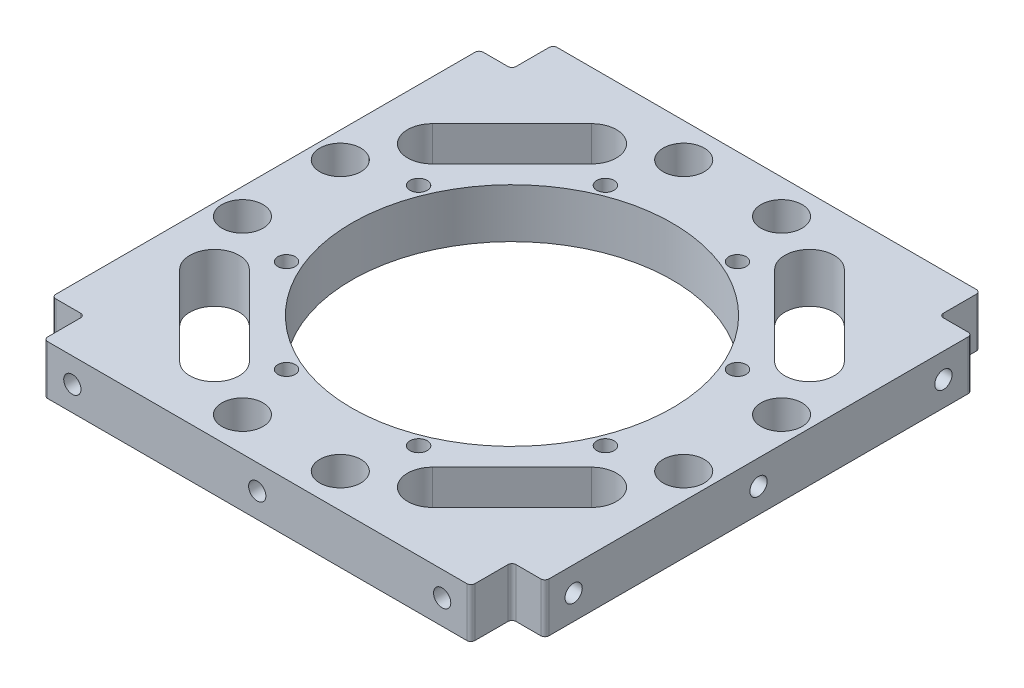
from build123d import *

# Parameters (mm, degrees)
SKETCH_1_W                  = 120
SKETCH_1_H                  = 124
SKETCH_1_R                  = 39
EXTRUDE_1_DEPTH             = 6
SKETCH_2_R                  = 2.1
CUT_EXTRUDE_1_DEPTH         = 13
PATTERN_CIRCULAR_1_COUNT    = 8
SKETCH_3_R                  = 1.5
CUT_EXTRUDE_2_DEPTH         = 15
SKETCH_4_R                  = 1.5
CUT_EXTRUDE_5_DEPTH         = 10
HOLE_WIZARD_M5_1_AT_2_COUNT = 2
HOLE_WIZARD_M5_1_AT_2_PITCH = 45
HOLE_WIZARD_M5_1_AT_3_COUNT = 2
HOLE_WIZARD_M5_1_AT_3_PITCH = 90
HOLE_WIZARD_M5_2_AT_2_COUNT = 2
HOLE_WIZARD_M5_2_AT_2_PITCH = 45
HOLE_WIZARD_M5_2_AT_3_COUNT = 2
HOLE_WIZARD_M5_2_AT_3_PITCH = 90
SKETCH_10_W                 = 8
SKETCH_10_H                 = 10
CUT_EXTRUDE_6_DEPTH         = 13
HOLE_WIZARD_M5_3_D          = 4.2
CUT_EXTRUDE_7_DEPTH         = 13
PATTERN_CIRCULAR_2_COUNT    = 4
SKETCH_13_R                 = 5
CUT_EXTRUDE_8_DEPTH         = 13
PATTERN_CIRCULAR_3_COUNT    = 4
FILLET_1_R                  = 1


with BuildPart() as part:
    # 草图1 → 凸台-拉伸1 (new body, symmetric)
    with BuildSketch(Plane(origin=(0, 0, 0), x_dir=(1, 0, 0), z_dir=(0, 1, 0))):
        Rectangle(SKETCH_1_W, SKETCH_1_H)
        Circle(SKETCH_1_R, mode=Mode.SUBTRACT)
    extrude(amount=EXTRUDE_1_DEPTH, both=True)

    # 草图2 → 切除-拉伸1 (cut, through all)
    with BuildSketch(Plane(origin=(0, 6, 0), x_dir=(1, 0, 0), z_dir=(0, 1, 0))):
        with Locations((-16.072704159, 38.802940365)):
            Circle(SKETCH_2_R)
    cut_extrude_1 = extrude(amount=-CUT_EXTRUDE_1_DEPTH, mode=Mode.SUBTRACT)

    # 阵列(圆周)1: 切除-拉伸1 ×8 about axis
    pattern_circular_1_axis = Axis((0, 0, 0), (0, 1, 0))
    for i in range(1, PATTERN_CIRCULAR_1_COUNT):
        add(cut_extrude_1.rotate(pattern_circular_1_axis, i * 360 / PATTERN_CIRCULAR_1_COUNT), mode=Mode.SUBTRACT)

    # 草图3 → 切除-拉伸2 (cut)
    with BuildSketch(Plane(origin=(60, 0, 0), x_dir=(0, 0, -1), z_dir=(1, 0, 0))):
        with Locations((-45, 0)):
            Circle(SKETCH_3_R)
        Circle(SKETCH_3_R)
        with Locations((45, 0)):
            Circle(SKETCH_3_R)
    cut_extrude_2 = extrude(amount=-CUT_EXTRUDE_2_DEPTH, mode=Mode.SUBTRACT)

    # 草图4 → 切除-拉伸5 (cut)
    with BuildSketch(Plane(origin=(0, 0, -62), x_dir=(-1, 0, 0), z_dir=(0, 0, -1))):
        with Locations((-45, 0)):
            Circle(SKETCH_4_R)
        Circle(SKETCH_4_R)
        with Locations((45, 0)):
            Circle(SKETCH_4_R)
    cut_extrude_5 = extrude(amount=-CUT_EXTRUDE_5_DEPTH, mode=Mode.SUBTRACT)

    # 草图7 → M5 螺纹孔1 (revolve, cut)
    with BuildSketch(Plane(origin=(60, 0, -45), x_dir=(0, 0, -1), z_dir=(0, 1, 0))):
        Polygon((0, 0), (0, 18.6618073), (2.1, 17.4), (2.1, 0), align=None)
    hole_wizard_m5_1 = revolve(axis=Axis((66.35, 0, -45), (-1, 0, 0)), mode=Mode.SUBTRACT)

    # M5 螺纹孔1 at 2: M5 螺纹孔1 ×2
    with Locations(*[(0, 0, i * HOLE_WIZARD_M5_1_AT_2_PITCH) for i in range(1, HOLE_WIZARD_M5_1_AT_2_COUNT)]):
        add(hole_wizard_m5_1, mode=Mode.SUBTRACT)

    # M5 螺纹孔1 at 3: M5 螺纹孔1 ×2
    with Locations(*[(0, 0, i * HOLE_WIZARD_M5_1_AT_3_PITCH) for i in range(1, HOLE_WIZARD_M5_1_AT_3_COUNT)]):
        add(hole_wizard_m5_1, mode=Mode.SUBTRACT)

    # 草图9 → M5 螺纹孔2 (revolve, cut)
    with BuildSketch(Plane(origin=(45, 0, -62), x_dir=(0, 1, 0), z_dir=(1, 0, 0))):
        Polygon((0, 0), (0, 13.6618073), (2.1, 12.4), (2.1, 0), align=None)
    hole_wizard_m5_2 = revolve(axis=Axis((45, 0, -68.35), (0, 0, 1)), mode=Mode.SUBTRACT)

    # M5 螺纹孔2 at 2: M5 螺纹孔2 ×2
    with Locations(*[(-i * HOLE_WIZARD_M5_2_AT_2_PITCH, 0, 0) for i in range(1, HOLE_WIZARD_M5_2_AT_2_COUNT)]):
        add(hole_wizard_m5_2, mode=Mode.SUBTRACT)

    # M5 螺纹孔2 at 3: M5 螺纹孔2 ×2
    with Locations(*[(-i * HOLE_WIZARD_M5_2_AT_3_PITCH, 0, 0) for i in range(1, HOLE_WIZARD_M5_2_AT_3_COUNT)]):
        add(hole_wizard_m5_2, mode=Mode.SUBTRACT)

    # 镜向1: M5 螺纹孔1, 切除-拉伸2 across plane
    add(hole_wizard_m5_1.mirror(Plane(origin=(0, 0, 0), x_dir=(0, 0, 1), z_dir=(1, 0, 0))), mode=Mode.SUBTRACT)
    add(cut_extrude_2.mirror(Plane(origin=(0, 0, 0), x_dir=(0, 0, 1), z_dir=(1, 0, 0))), mode=Mode.SUBTRACT)

    # 镜向1 copy 1 sketch → 镜向1 copy 1 (revolve, cut)
    with BuildSketch(Plane(origin=(-60, 0, 0), x_dir=(0, 0, -1), z_dir=(0, 1, 0))):
        Polygon((0, 0), (0, -18.6618073), (2.1, -17.4), (2.1, 0), align=None)
    revolve(axis=Axis((-66.35, 0, 0), (-1, 0, 0)), mode=Mode.SUBTRACT)

    # 镜向1 copy 2 sketch → 镜向1 copy 2 (revolve, cut)
    with BuildSketch(Plane(origin=(-60, 0, 45), x_dir=(0, 0, -1), z_dir=(0, 1, 0))):
        Polygon((0, 0), (0, -18.6618073), (2.1, -17.4), (2.1, 0), align=None)
    revolve(axis=Axis((-66.35, 0, 45), (-1, 0, 0)), mode=Mode.SUBTRACT)

    # 镜向2: M5 螺纹孔2, 切除-拉伸5 across plane
    add(hole_wizard_m5_2.mirror(Plane.XY), mode=Mode.SUBTRACT)
    add(cut_extrude_5.mirror(Plane.XY), mode=Mode.SUBTRACT)

    # 镜向2 copy 1 sketch → 镜向2 copy 1 (revolve, cut)
    with BuildSketch(Plane(origin=(0, 0, 62), x_dir=(0, 1, 0), z_dir=(1, 0, 0))):
        Polygon((0, 0), (0, -13.6618073), (2.1, -12.4), (2.1, 0), align=None)
    revolve(axis=Axis((0, 0, 68.35), (0, 0, 1)), mode=Mode.SUBTRACT)

    # 镜向2 copy 2 sketch → 镜向2 copy 2 (revolve, cut)
    with BuildSketch(Plane(origin=(-45, 0, 62), x_dir=(0, 1, 0), z_dir=(1, 0, 0))):
        Polygon((0, 0), (0, -13.6618073), (2.1, -12.4), (2.1, 0), align=None)
    revolve(axis=Axis((-45, 0, 68.35), (0, 0, 1)), mode=Mode.SUBTRACT)

    # 草图10 → 切除-拉伸6 (cut, through all)
    with BuildSketch(Plane.XZ.offset(6)):
        with Locations((-56, 57)):
            Rectangle(SKETCH_10_W, SKETCH_10_H)
        with Locations((56, 57)):
            Rectangle(SKETCH_10_W, SKETCH_10_H)
        with Locations((56, -57)):
            Rectangle(SKETCH_10_W, SKETCH_10_H)
        with Locations((-56, -57)):
            Rectangle(SKETCH_10_W, SKETCH_10_H)
    extrude(amount=-CUT_EXTRUDE_6_DEPTH, mode=Mode.SUBTRACT)

    # M5 螺纹孔3 (through all)
    with Locations(Plane(origin=(16.072704159, 6, -38.802940365), x_dir=(0, 0, 1), z_dir=(0, 1, 0))):
        with Locations((0, 0), (22.730236206, 22.730236206), (54.875644524, 22.730236206), (77.60588073, 0), (77.60588073, -32.145408318), (54.875644524, -54.875644524), (22.730236206, -54.875644524), (0, -32.145408318)):
            Hole(HOLE_WIZARD_M5_3_D / 2)

    # 草图12 → 切除-拉伸7 (cut, through all)
    with BuildSketch(Plane.XZ.offset(6)):
        with BuildLine():
            Line((22.257359313, -41.656705713), (41.656705713, -22.257359313))
            ThreePointArc((41.656705713, -22.257359313), (50.141987088, -22.257359313), (50.141987088, -30.742640687))
            Line((50.141987088, -30.742640687), (30.742640687, -50.141987088))
            ThreePointArc((30.742640687, -50.141987088), (22.257359313, -50.141987088), (22.257359313, -41.656705713))
        make_face()
    cut_extrude_7 = extrude(amount=-CUT_EXTRUDE_7_DEPTH, mode=Mode.SUBTRACT)

    # 阵列(圆周)2: 切除-拉伸7 ×4 about axis
    pattern_circular_2_axis = Axis((0, 0, 0), (0, 1, 0))
    for i in range(1, PATTERN_CIRCULAR_2_COUNT):
        add(cut_extrude_7.rotate(pattern_circular_2_axis, i * 360 / PATTERN_CIRCULAR_2_COUNT), mode=Mode.SUBTRACT)

    # 草图13 → 切除-拉伸8 (cut, through all)
    with BuildSketch(Plane.XZ.offset(6)):
        with Locations((11.904178767, 53.696280392)):
            Circle(SKETCH_13_R)
        with Locations((-11.904178767, 53.696280392)):
            Circle(SKETCH_13_R)
    cut_extrude_8 = extrude(amount=-CUT_EXTRUDE_8_DEPTH, mode=Mode.SUBTRACT)

    # 阵列(圆周)3: 切除-拉伸8 ×4 about axis
    pattern_circular_3_axis = Axis((0, 0, 0), (0, 1, 0))
    for i in range(1, PATTERN_CIRCULAR_3_COUNT):
        add(cut_extrude_8.rotate(pattern_circular_3_axis, i * 360 / PATTERN_CIRCULAR_3_COUNT), mode=Mode.SUBTRACT)

    # 圆角1
    fillet_1_edges = [part.edges().sort_by_distance(p)[0] for p in [
        (-60, 0, -52),
        (-52, 0, -52),
        (-52, 0, -62),
        (60, 0, -52),
        (52, 0, -62),
        (52, 0, -52),
        (60, 0, 52),
        (52, 0, 52),
        (52, 0, 62),
        (-60, 0, 52),
        (-52, 0, 62),
        (-52, 0, 52),
    ]]
    fillet(fillet_1_edges, radius=FILLET_1_R)


solid = part.part
